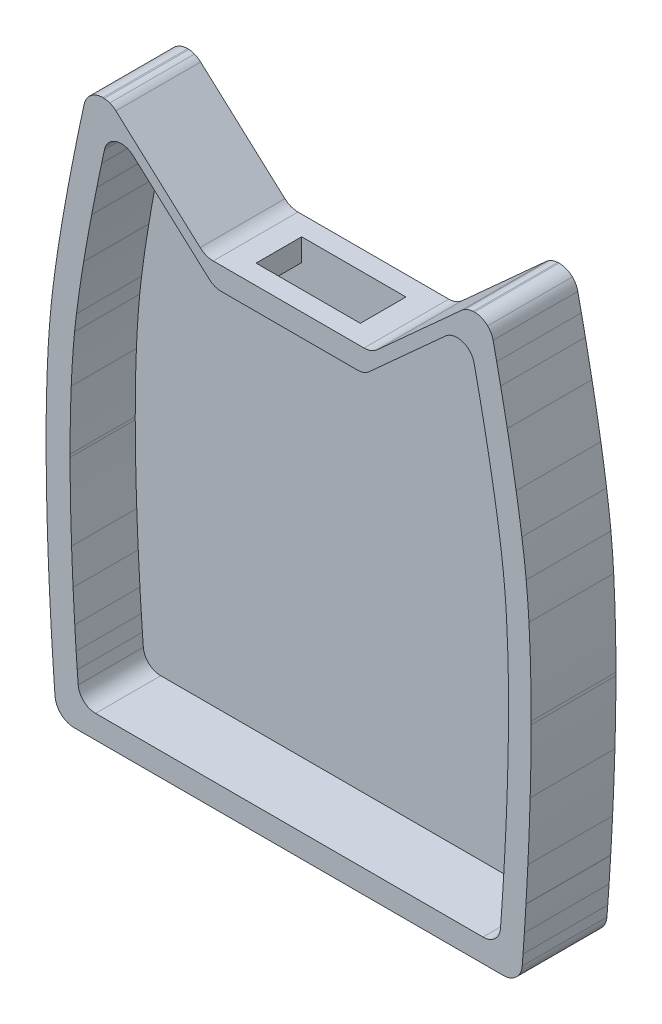
from build123d import *

# Parameters (mm, degrees)
BOSS_EXTRUDE1_DEPTH = 13
CUT_EXTRUDE1_DEPTH  = 10
SKETCH3_W           = 16
SKETCH3_H           = 7
CUT_EXTRUDE2_DEPTH  = 10


with BuildPart() as part:
    # Sketch1 → Boss-Extrude1 (new body)
    with BuildSketch(Plane.XY):
        with BuildLine():
            Line((-74610.450441655, -128792.810070468), (-74623.380905288, -128804.509702016))
            ThreePointArc((-74623.380905288, -128804.509702016), (-74624.311665462, -128805.082407925), (-74625.386088015, -128805.282214672))
            Line((-74625.386088015, -128805.282214672), (-74648.527571373, -128805.282214672))
            ThreePointArc((-74648.527571373, -128805.282214672), (-74649.601994385, -128805.082407411), (-74650.532755515, -128804.509702016))
            Line((-74650.532755515, -128804.509702016), (-74663.463212078, -128792.810070468))
            ThreePointArc((-74663.463212078, -128792.810070468), (-74663.905274117, -128792.476386452), (-74664.401065449, -128792.229496142))
            ThreePointArc((-74664.401065449, -128792.229496142), (-74664.81496712, -128792.104507427), (-74665.242797903, -128792.04207671))
            ThreePointArc((-74665.242797903, -128792.04207671), (-74665.347394332, -128792.036500317), (-74665.452122834, -128792.034642934))
            ThreePointArc((-74665.452122834, -128792.034642934), (-74667.070013046, -128792.51277605), (-74668.155385668, -128793.804343426))
            ThreePointArc((-74668.155385668, -128793.804343426), (-74668.2548634, -128794.073784255), (-74668.328475138, -128794.351408986))
            ThreePointArc((-74668.328475138, -128794.351408986), (-74668.571976193, -128795.483107184), (-74668.812679844, -128796.615403667))
            ThreePointArc((-74668.812679844, -128796.615403667), (-74669.224891789, -128798.587183702), (-74669.628524604, -128800.560737793))
            ThreePointArc((-74669.628524604, -128800.560737793), (-74670.070837499, -128802.777521087), (-74670.501251993, -128804.996645291))
            ThreePointArc((-74670.501251993, -128804.996645291), (-74671.203834336, -128808.780456947), (-74671.862477846, -128812.572163862))
            ThreePointArc((-74671.862477846, -128812.572163862), (-74672.517039323, -128816.706395515), (-74673.086233081, -128820.853242577))
            ThreePointArc((-74673.086233081, -128820.853242577), (-74673.252886192, -128822.253201992), (-74673.403620183, -128823.65496477))
            ThreePointArc((-74673.403620183, -128823.65496477), (-74673.748707657, -128827.790386536), (-74673.973711381, -128831.934077146))
            ThreePointArc((-74673.973711381, -128831.934077146), (-74674.12510952, -128836.985676085), (-74674.170537572, -128842.039339066))
            ThreePointArc((-74674.170537572, -128842.039339066), (-74674.170442355, -128842.279063933), (-74674.170157877, -128842.518788651))
            ThreePointArc((-74674.170157877, -128842.518788651), (-74674.096836764, -128848.9730921), (-74673.913272745, -128855.425201308))
            ThreePointArc((-74673.913272745, -128855.425201308), (-74673.796388653, -128858.39947501), (-74673.660888287, -128861.372958757))
            ThreePointArc((-74673.660888287, -128861.372958757), (-74673.523956771, -128864.043943834), (-74673.373091807, -128866.714178146))
            ThreePointArc((-74673.373091807, -128866.714178146), (-74673.258356057, -128868.597866422), (-74673.13673875, -128870.481122922))
            ThreePointArc((-74673.13673875, -128870.481122922), (-74673.046982794, -128871.805733558), (-74672.953641295, -128873.13009636))
            ThreePointArc((-74672.953641295, -128873.13009636), (-74672.875630698, -128874.198024695), (-74672.795008742, -128875.265759065))
            ThreePointArc((-74672.795008742, -128875.265759065), (-74671.850444269, -128877.201903593), (-74669.839445541, -128877.974394237))
            Line((-74669.839445541, -128877.974394237), (-74604.074209606, -128877.974394237))
            ThreePointArc((-74604.074209606, -128877.974394237), (-74602.06320992, -128877.201904034), (-74601.118645197, -128875.265758809))
            ThreePointArc((-74601.118645197, -128875.265758809), (-74601.055541877, -128874.433100734), (-74600.994052257, -128873.600321936))
            ThreePointArc((-74600.994052257, -128873.600321936), (-74600.890470815, -128872.148401278), (-74600.791248483, -128870.696176213))
            ThreePointArc((-74600.791248483, -128870.696176213), (-74600.66417319, -128868.739016589), (-74600.544538695, -128866.781388046))
            ThreePointArc((-74600.544538695, -128866.781388046), (-74600.542549099, -128866.747771572), (-74600.540561692, -128866.714154968))
            ThreePointArc((-74600.540561692, -128866.714154968), (-74600.389697071, -128864.043922578), (-74600.252765778, -128861.372939431))
            ThreePointArc((-74600.252765778, -128861.372939431), (-74600.05324975, -128856.830863133), (-74599.89853531, -128852.287040162))
            ThreePointArc((-74599.89853531, -128852.287040162), (-74599.787976307, -128847.403438749), (-74599.743496671, -128842.518788545))
            ThreePointArc((-74599.743496671, -128842.518788545), (-74599.74321218, -128842.27905782), (-74599.743116951, -128842.039326945))
            ThreePointArc((-74599.743116951, -128842.039326945), (-74599.819370757, -128835.556973637), (-74600.083700761, -128829.079562988))
            ThreePointArc((-74600.083700761, -128829.079562988), (-74600.268530886, -128826.365036838), (-74600.510032755, -128823.654964655))
            ThreePointArc((-74600.510032755, -128823.654964655), (-74600.814158665, -128820.959866435), (-74601.170105688, -128818.271121616))
            ThreePointArc((-74601.170105688, -128818.271121616), (-74601.592401033, -128815.418822882), (-74602.051176356, -128812.572164029))
            ThreePointArc((-74602.051176356, -128812.572164029), (-74602.709815923, -128808.780480062), (-74603.412393576, -128804.996691216))
            ThreePointArc((-74603.412393576, -128804.996691216), (-74603.911602003, -128802.428793957), (-74604.42658495, -128799.864013663))
            ThreePointArc((-74604.42658495, -128799.864013663), (-74604.729184903, -128798.391926097), (-74605.036544313, -128796.920824902))
            ThreePointArc((-74605.036544313, -128796.920824902), (-74605.309060799, -128795.635732593), (-74605.585176168, -128794.351408732))
            ThreePointArc((-74605.585176168, -128794.351408732), (-74605.888548655, -128793.536512019), (-74606.419287008, -128792.847738964))
            ThreePointArc((-74606.419287008, -128792.847738964), (-74607.362322728, -128792.245064573), (-74608.461529521, -128792.03464305))
            ThreePointArc((-74608.461529521, -128792.03464305), (-74608.566259555, -128792.036500435), (-74608.670857509, -128792.042076976))
            ThreePointArc((-74608.670857509, -128792.042076976), (-74609.367593169, -128792.178013712), (-74610.010959738, -128792.478011767))
            ThreePointArc((-74610.010959738, -128792.478011767), (-74610.238131281, -128792.634206689), (-74610.450441655, -128792.810070468))
        make_face()
    extrude(amount=BOSS_EXTRUDE1_DEPTH)

    # Sketch2 → Cut-Extrude1 (cut)
    with BuildSketch(Plane.XY.offset(13)):
        with BuildLine():
            Line((-74612.896883724, -128797.442043359), (-74624.584556737, -128808.017183724))
            ThreePointArc((-74624.584556737, -128808.017183724), (-74625.425858398, -128808.534844934), (-74626.397014563, -128808.715447584))
            Line((-74626.397014563, -128808.715447584), (-74647.314291639, -128808.715447584))
            ThreePointArc((-74647.314291639, -128808.715447584), (-74648.28544822, -128808.534844481), (-74649.126750751, -128808.017183744))
            Line((-74649.126750751, -128808.017183744), (-74660.814417373, -128797.44204338))
            ThreePointArc((-74660.814417373, -128797.44204338), (-74661.21399135, -128797.140430891), (-74661.662130509, -128796.917270073))
            ThreePointArc((-74661.662130509, -128796.917270073), (-74662.036250678, -128796.804294433), (-74662.422961185, -128796.747864129))
            ThreePointArc((-74662.422961185, -128796.747864129), (-74662.51750449, -128796.742823687), (-74662.612167174, -128796.741144808))
            ThreePointArc((-74662.612167174, -128796.741144808), (-74664.074556498, -128797.173322929), (-74665.055610297, -128798.340753402))
            ThreePointArc((-74665.055610297, -128798.340753402), (-74665.145526836, -128798.584297246), (-74665.212063471, -128798.835238403))
            ThreePointArc((-74665.212063471, -128798.835238403), (-74665.432160842, -128799.858165489), (-74665.649729677, -128800.881633357))
            ThreePointArc((-74665.649729677, -128800.881633357), (-74666.022322504, -128802.663898833), (-74666.38716077, -128804.447767854))
            ThreePointArc((-74666.38716077, -128804.447767854), (-74666.786961489, -128806.451488687), (-74667.176007401, -128808.457325437))
            ThreePointArc((-74667.176007401, -128808.457325437), (-74667.811062193, -128811.877462178), (-74668.40640126, -128815.304735337))
            ThreePointArc((-74668.40640126, -128815.304735337), (-74668.998050622, -128819.041611904), (-74669.51253725, -128822.789891369))
            ThreePointArc((-74669.51253725, -128822.789891369), (-74669.663172764, -128824.055295919), (-74669.7994192, -128825.322330506))
            ThreePointArc((-74669.7994192, -128825.322330506), (-74670.11133917, -128829.060282937), (-74670.314717043, -128832.805709466))
            ThreePointArc((-74670.314717043, -128832.805709466), (-74670.451563804, -128837.371782103), (-74670.492625624, -128841.939720399))
            ThreePointArc((-74670.492625624, -128841.939720399), (-74670.492539577, -128842.156404489), (-74670.492282459, -128842.373088444))
            ThreePointArc((-74670.492282459, -128842.373088444), (-74670.426008488, -128848.207046922), (-74670.26008743, -128854.039022056))
            ThreePointArc((-74670.26008743, -128854.039022056), (-74670.154437485, -128856.72742827), (-74670.031960537, -128859.415120454))
            ThreePointArc((-74670.031960537, -128859.415120454), (-74669.908189974, -128861.829388241), (-74669.771825151, -128864.242977422))
            ThreePointArc((-74669.771825151, -128864.242977422), (-74669.668116945, -128865.94561801), (-74669.558188592, -128867.647868321))
            ThreePointArc((-74669.558188592, -128867.647868321), (-74669.477059379, -128868.845166195), (-74669.392689241, -128870.042240056))
            ThreePointArc((-74669.392689241, -128870.042240056), (-74669.322176532, -128871.007526023), (-74669.249303451, -128871.972636667))
            ThreePointArc((-74669.249303451, -128871.972636667), (-74668.395524242, -128873.722691794), (-74666.577809392, -128874.420935744))
            Line((-74666.577809392, -128874.420935744), (-74607.13349285, -128874.420935744))
            ThreePointArc((-74607.13349285, -128874.420935744), (-74605.315777227, -128873.722692266), (-74604.461997753, -128871.972636653))
            ThreePointArc((-74604.461997753, -128871.972636653), (-74604.404959496, -128871.220008101), (-74604.349379841, -128870.46727043))
            ThreePointArc((-74604.349379841, -128870.46727043), (-74604.255753949, -128869.15489886), (-74604.166068197, -128867.842252139))
            ThreePointArc((-74604.166068197, -128867.842252139), (-74604.051206504, -128866.073201445), (-74603.94307045, -128864.303726901))
            ThreePointArc((-74603.94307045, -128864.303726901), (-74603.941272104, -128864.273341609), (-74603.939475738, -128864.2429562))
            ThreePointArc((-74603.939475738, -128864.2429562), (-74603.803111232, -128861.829368957), (-74603.679340873, -128859.415103115))
            ThreePointArc((-74603.679340873, -128859.415103115), (-74603.499001007, -128855.309581254), (-74603.359156694, -128851.202480599))
            ThreePointArc((-74603.359156694, -128851.202480599), (-74603.259223884, -128846.788258324), (-74603.219019339, -128842.373088061))
            ThreePointArc((-74603.219019339, -128842.373088061), (-74603.218762221, -128842.156398819), (-74603.218676174, -128841.939709442))
            ThreePointArc((-74603.218676174, -128841.939709442), (-74603.287601003, -128836.080396891), (-74603.5265254, -128830.225551946))
            ThreePointArc((-74603.5265254, -128830.225551946), (-74603.693590885, -128827.771928244), (-74603.911881195, -128825.322330423))
            ThreePointArc((-74603.911881195, -128825.322330423), (-74604.186776514, -128822.886267219), (-74604.508512244, -128820.455946768))
            ThreePointArc((-74604.508512244, -128820.455946768), (-74604.890219391, -128817.877792009), (-74605.304900305, -128815.304735063))
            ThreePointArc((-74605.304900305, -128815.304735063), (-74605.900235797, -128811.877482761), (-74606.535286336, -128808.457366753))
            ThreePointArc((-74606.535286336, -128808.457366753), (-74606.98651409, -128806.13627895), (-74607.452000218, -128803.818008529))
            ThreePointArc((-74607.452000218, -128803.818008529), (-74607.725516239, -128802.487408335), (-74608.003334271, -128801.157699708))
            ThreePointArc((-74608.003334271, -128801.157699708), (-74608.249658342, -128799.99612166), (-74608.499235398, -128798.835238201))
            ThreePointArc((-74608.499235398, -128798.835238201), (-74608.773449741, -128798.098664083), (-74609.253176987, -128797.476091432))
            ThreePointArc((-74609.253176987, -128797.476091432), (-74610.105574351, -128796.931342095), (-74611.099132667, -128796.74114488))
            ThreePointArc((-74611.099132667, -128796.74114488), (-74611.193796747, -128796.74282376), (-74611.288341442, -128796.747864335))
            ThreePointArc((-74611.288341442, -128796.747864335), (-74611.918111468, -128796.870735736), (-74612.499641887, -128797.141899962))
            ThreePointArc((-74612.499641887, -128797.141899962), (-74612.704979211, -128797.283082452), (-74612.896883724, -128797.442043359))
        make_face()
    extrude(amount=-CUT_EXTRUDE1_DEPTH, mode=Mode.SUBTRACT)

    # Sketch3 → Cut-Extrude2 (cut)
    with BuildSketch(Plane(origin=(0, -128805.282214672, 0), x_dir=(1, 0, 0), z_dir=(0, 1, 0))):
        with Locations((-74636.956088015, -6.5)):
            Rectangle(SKETCH3_W, SKETCH3_H)
    extrude(amount=-CUT_EXTRUDE2_DEPTH, mode=Mode.SUBTRACT)


solid = part.part
